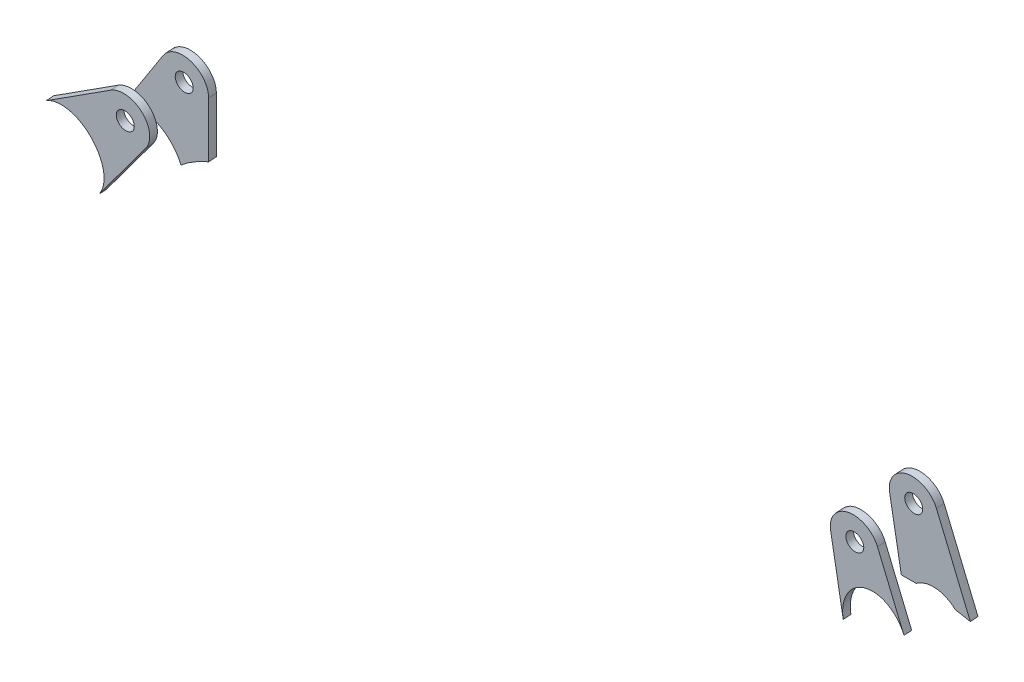
from build123d import *

# Parameters (mm, degrees)
SZKIC1_R                      = 3.5
DODANIE_WYCI_GNI_CIE1_DEPTH   = 3
DODANIE_WYCI_GNI_CIE1_2_DEPTH = 3
SZKIC2_R                      = 3.5
DODANIE_WYCI_GNI_CIE2_DEPTH   = 3
DODANIE_WYCI_GNI_CIE2_2_DEPTH = 3


with BuildPart() as part:
    # Szkic1 → Dodanie-wyciągnięcie1 (new body)
    with BuildSketch(Plane(origin=(0, -7.25805409, 114.747845399), x_dir=(-1, 0, 0), z_dir=(0, 0.063126051, -0.998005562))):
        with BuildLine():
            ThreePointArc((-1469.550369154, 256.162669348), (-1477.021998182, 266.4314406), (-1488.028232153, 260.096164982))
            Line((-1488.028232153, 260.096164982), (-1496.682707646, 233.668286007))
            add(Edge.make_bspline(
                [(-1496.682707646, 233.668286007), (-1494.549268537, 240.183096826), (-1489.671600164, 243.027652706), (-1485, 243.027652706), (-1478.171550536, 243.027652706), (-1471.493308251, 237.369876498), (-1472.589244959, 226.769589758)],
                knots=[0.295959603, 0.295959603, 0.295959603, 0.295959603, 0.5, 0.5, 0.5, 0.76496368, 0.76496368, 0.76496368, 0.76496368], degree=3, weights=[0.516898281, 0.56691223, 0.727946137, 1, 0.646715093, 0.480645525, 0.501791294]))
            Line((-1472.589244959, 226.769589758), (-1469.550369154, 256.162669348))
        make_face()
        with Locations((-1479, 257.139642668)):
            Circle(SZKIC1_R, mode=Mode.SUBTRACT)
    extrude(amount=-DODANIE_WYCI_GNI_CIE1_DEPTH)


with BuildPart() as body_2:
    # Szkic1 → Dodanie-wyci_gni_cie1 2 (new body)
    with BuildSketch(Plane(origin=(0, -7.25805409, 114.747845399), x_dir=(-1, 0, 0), z_dir=(0, 0.063126051, -0.998005562))):
        with BuildLine():
            Line((-1163.559881906, 247.826017638), (-1189.778452634, 265.07597955))
            ThreePointArc((-1189.778452634, 265.07597955), (-1201.931051804, 263.636605104), (-1202.582523544, 251.416414846))
            Line((-1202.582523544, 251.416414846), (-1182.76254688, 225.157554572))
            add(Edge.make_bspline(
                [(-1182.76254688, 225.157554572), (-1195.705807464, 242.305671187), (-1178.155883632, 257.429152624), (-1163.559881906, 247.826017638)],
                knots=[0.562562367, 0.562562367, 0.562562367, 0.562562367, 0.999146732, 0.999146732, 0.999146732, 0.999146732], degree=3, weights=[0.781062929, 0.344623783, 0.416467058, 0.996592754]))
        make_face()
        with Locations((-1195, 257.139642668)):
            Circle(SZKIC1_R, mode=Mode.SUBTRACT)
    extrude(amount=-DODANIE_WYCI_GNI_CIE1_2_DEPTH)


with BuildPart() as body_3:
    # Szkic2 → Dodanie-wyciągnięcie2 (new body)
    with BuildSketch(Plane(origin=(0, -5.995533068, 94.78773416), x_dir=(-1, 0, 0), z_dir=(0, 0.063126051, -0.998005562))):
        with BuildLine():
            add(Edge.make_bspline(
                [(-1499.081969424, 226.341741496), (-1497.164459003, 226.72545054), (-1495.249800372, 227.106857649), (-1493.338408358, 227.485899627)],
                knots=[0.978069865, 0.978069865, 0.978069865, 0.978069865, 0.987766131, 0.987766131, 0.987766131, 0.987766131], degree=3, weights=[0.974357504, 0.977963363, 0.981645873, 0.985405033]))
            add(Edge.make_bspline(
                [(-1493.338408358, 227.485899627), (-1488.968930095, 232.032323973), (-1483.121424188, 232.560272537), (-1478.200062015, 228.852682039)],
                knots=[0, 0, 0, 0, 1, 1, 1, 1], degree=3, weights=[1, 0.862951749, 0.862951749, 1]))
            add(Edge.make_bspline(
                [(-1478.200062015, 228.852682039), (-1476.26470701, 228.840500886), (-1474.323901246, 228.827162356), (-1472.378018702, 228.812644683)],
                knots=[0.015705516, 0.015705516, 0.015705516, 0.015705516, 0.02688398, 0.02688398, 0.02688398, 0.02688398], degree=3, weights=[0.970194637, 0.963236106, 0.956357884, 0.94955997]))
            Line((-1472.378018702, 228.812644683), (-1469.550369154, 256.162669348))
            ThreePointArc((-1469.550369154, 256.162669348), (-1477.021998182, 266.4314406), (-1488.028232153, 260.096164982))
            Line((-1488.028232153, 260.096164982), (-1499.081969424, 226.341741496))
        make_face()
        with Locations((-1479, 257.139642668)):
            Circle(SZKIC2_R, mode=Mode.SUBTRACT)
    extrude(amount=DODANIE_WYCI_GNI_CIE2_DEPTH)


with BuildPart() as body_4:
    # Szkic2 → Dodanie-wyci_gni_cie2 2 (new body)
    with BuildSketch(Plane(origin=(0, -5.995533068, 94.78773416), x_dir=(-1, 0, 0), z_dir=(0, 0.063126051, -0.998005562))):
        with BuildLine():
            ThreePointArc((-1187.086998027, 262.396485806), (-1198.029684937, 266.143586758), (-1204.481282298, 256.543583953))
            Line((-1204.481282298, 256.543583953), (-1203.036946157, 233.569070978))
            add(Edge.make_bspline(
                [(-1203.036946157, 233.569070978), (-1198.394891016, 231.545198423), (-1194.600848133, 229.118580489), (-1191.830864188, 226.535755676)],
                knots=[0.780966017, 0.780966017, 0.780966017, 0.780966017, 0.856944696, 0.856944696, 0.856944696, 0.856944696], degree=3, weights=[0.507671154, 0.520219191, 0.548161255, 0.591497344]))
            add(Edge.make_bspline(
                [(-1191.830864188, 226.535755676), (-1187.789848964, 239.236197933), (-1175.216880476, 244.52867786), (-1167.979845348, 233.634939595)],
                knots=[0, 0, 0, 0, 0.413856164, 0.413856164, 0.413856164, 0.413856164], degree=3, weights=[1, 0.591861089, 0.521543786, 0.789048091]))
            Line((-1167.979845348, 233.634939595), (-1187.086998027, 262.396485806))
        make_face()
        with Locations((-1195, 257.139642668)):
            Circle(SZKIC2_R, mode=Mode.SUBTRACT)
    extrude(amount=DODANIE_WYCI_GNI_CIE2_2_DEPTH)


solid = Compound([part.part, body_2.part, body_3.part, body_4.part])
